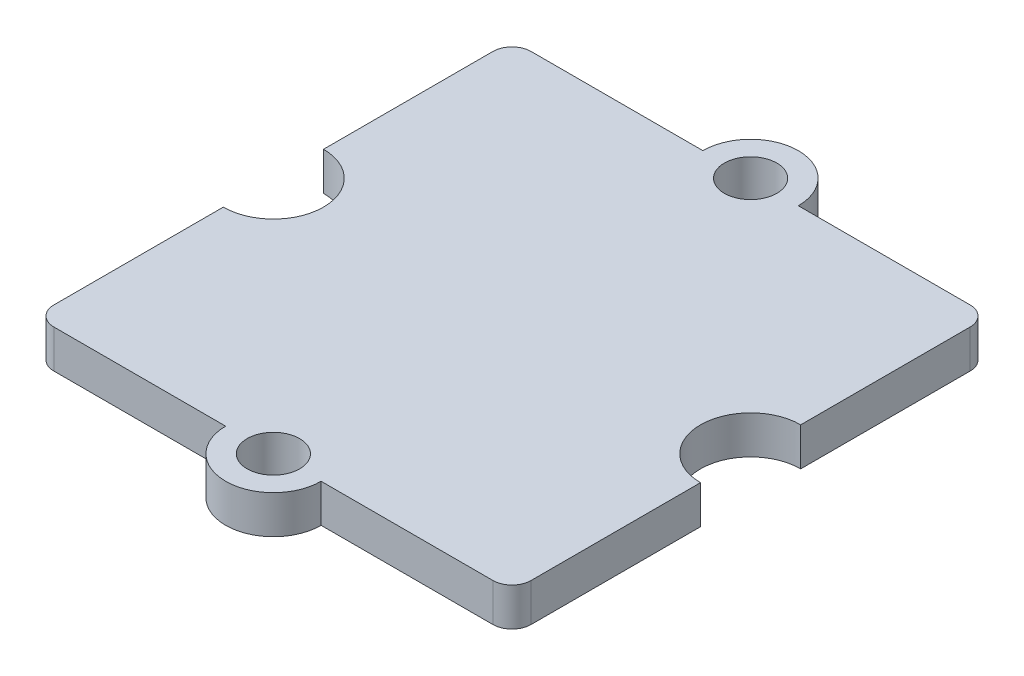
from build123d import *

# Parameters (mm, degrees)
ESQUISSE1_R        = 1.1
BOSS_EXTRU_1_DEPTH = 0.8


with BuildPart() as part:
    # Esquisse1 → Boss.-Extru.1 (new body, symmetric)
    with BuildSketch(Plane(origin=(0, 0, 0), x_dir=(1, 0, 0), z_dir=(0, 1, 0))):
        with BuildLine():
            ThreePointArc((-2, -10), (0, -12), (2, -10))
            Line((2, -10), (9.2, -10))
            ThreePointArc((9.2, -10), (9.765685425, -9.765685425), (10, -9.2))
            Line((10, -9.2), (10, -2.1))
            ThreePointArc((10, -2.1), (7.9, 0), (10, 2.1))
            Line((10, 2.1), (10, 9.2))
            ThreePointArc((10, 9.2), (9.765685425, 9.765685425), (9.2, 10))
            Line((9.2, 10), (2, 10))
            ThreePointArc((2, 10), (0, 12), (-2, 10))
            Line((-2, 10), (-9.2, 10))
            ThreePointArc((-9.2, 10), (-9.765685425, 9.765685425), (-10, 9.2))
            Line((-10, 9.2), (-10, 2.1))
            ThreePointArc((-10, 2.1), (-7.9, 0), (-10, -2.1))
            Line((-10, -2.1), (-10, -9.2))
            ThreePointArc((-10, -9.2), (-9.765685425, -9.765685425), (-9.2, -10))
            Line((-9.2, -10), (-2, -10))
        make_face()
        with Locations((0, -10)):
            Circle(ESQUISSE1_R, mode=Mode.SUBTRACT)
        with Locations((0, 10)):
            Circle(ESQUISSE1_R, mode=Mode.SUBTRACT)
    extrude(amount=BOSS_EXTRU_1_DEPTH, both=True)


solid = part.part
